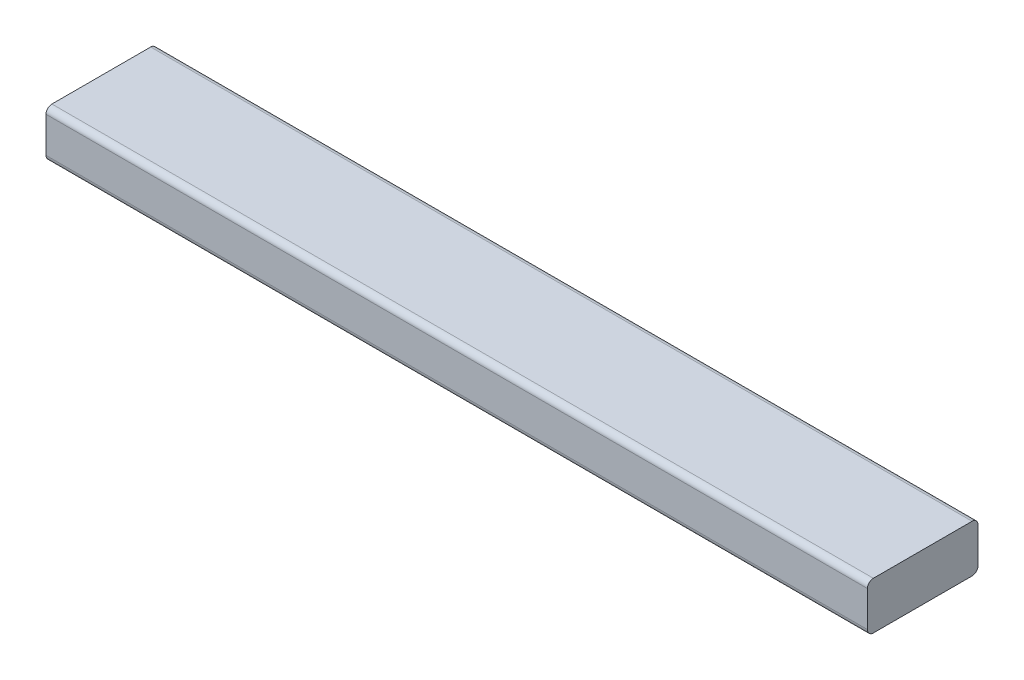
from build123d import *

# Parameters (mm, degrees)
SKETCH1_W           = 660.4
SKETCH1_H           = 88.9
BOSS_EXTRUDE1_DEPTH = 38.1
FILLET1_R           = 4.7625


with BuildPart() as part:
    # Sketch1 → Boss-Extrude1 (new body)
    with BuildSketch(Plane(origin=(0, 0, 0), x_dir=(1, 0, 0), z_dir=(0, 1, 0))):
        Rectangle(SKETCH1_W, SKETCH1_H)
    extrude(amount=BOSS_EXTRUDE1_DEPTH)

    # Fillet1
    fillet1_edges = [part.edges().sort_by_distance(p)[0] for p in [
        (0, 38.1, 44.45),
        (0, 0, 44.45),
        (0, 0, -44.45),
        (0, 38.1, -44.45),
    ]]
    fillet(fillet1_edges, radius=FILLET1_R)


solid = part.part
